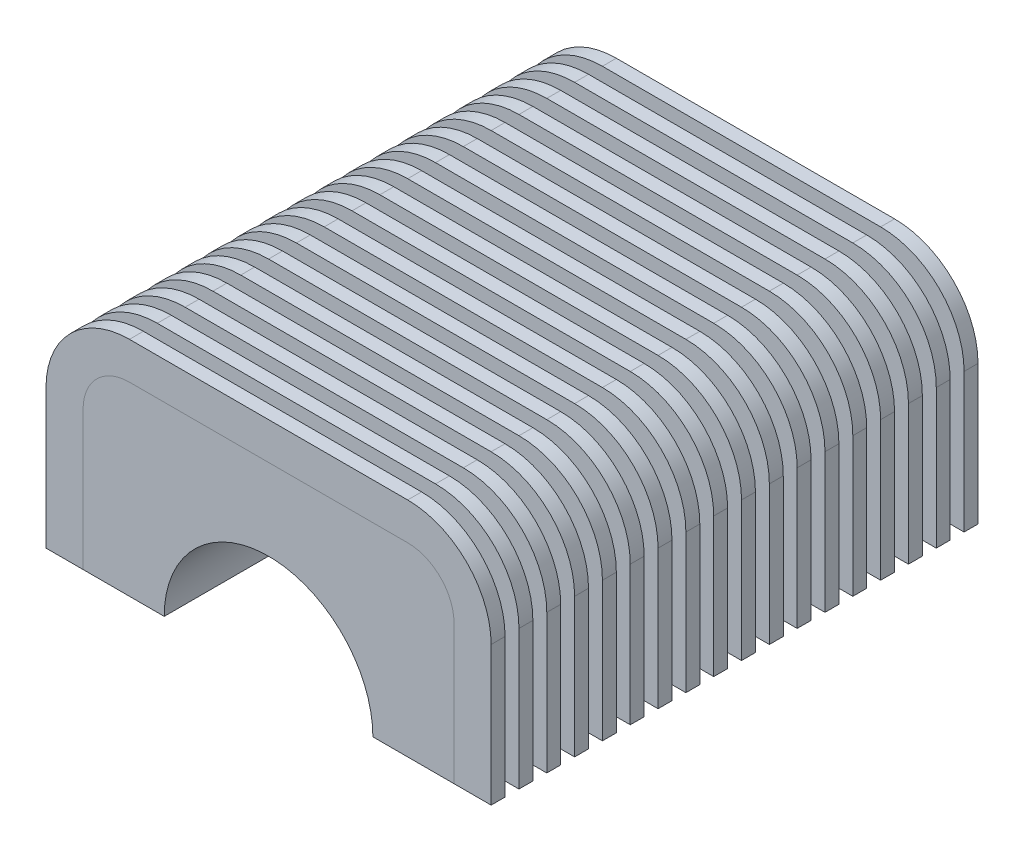
from build123d import *

# Parameters (mm, degrees)
DODANIE_WYCI_GNI_CIE1_DEPTH = 108
ZAOKR_GLENIE1_R             = 10
ZAOKR_GLENIE3_R             = 10
DODANIE_WYCI_GNI_CIE4_DEPTH = 3
SZYK_LINIOWY4_COUNT         = 18
SZYK_LINIOWY4_PITCH         = 6


with BuildPart() as part:
    # Szkic2 → Dodanie-wyciągnięcie1 (new body)
    with BuildSketch(Plane.XY):
        with BuildLine():
            Line((-40, 0), (-22.5, 0))
            ThreePointArc((-22.5, 0), (0, 22.5), (22.5, 0))
            Line((22.5, 0), (40, 0))
            Line((40, 0), (40, 40))
            Line((40, 40), (-40, 40))
            Line((-40, 40), (-40, 0))
        make_face()
    extrude(amount=-DODANIE_WYCI_GNI_CIE1_DEPTH)

    # Zaokrąglenie1
    zaokr_glenie1_edges = [part.edges().sort_by_distance(p)[0] for p in [
        (-40, 40, -54),
    ]]
    fillet(zaokr_glenie1_edges, radius=ZAOKR_GLENIE1_R)

    # Zaokrąglenie3
    zaokr_glenie3_edges = [part.edges().sort_by_distance(p)[0] for p in [
        (40, 40, -54),
    ]]
    fillet(zaokr_glenie3_edges, radius=ZAOKR_GLENIE3_R)


with BuildPart() as body_2:
    # Szkic3 → Dodanie-wyciągnięcie4 (new body)
    with BuildSketch(Plane.XY):
        with BuildLine():
            Line((-40, 0), (-48, 0))
            Line((-48, 0), (-48, 30))
            ThreePointArc((-48, 30), (-42.727922061, 42.727922061), (-30, 48))
            Line((-30, 48), (30, 48))
            ThreePointArc((30, 48), (42.727922061, 42.727922061), (48, 30))
            Line((48, 30), (48, 0))
            Line((48, 0), (40, 0))
            Line((40, 0), (40, 30))
            ThreePointArc((40, 30), (37.071067812, 37.071067812), (30, 40))
            Line((30, 40), (-30, 40))
            ThreePointArc((-30, 40), (-37.071067812, 37.071067812), (-40, 30))
            Line((-40, 30), (-40, 0))
        make_face()
    dodanie_wyci_gni_cie4 = extrude(amount=-DODANIE_WYCI_GNI_CIE4_DEPTH)


with BuildPart() as szyk_liniowy4_1:
    # Szyk liniowy4: Dodanie-wyciągnięcie4 ×18
    with Locations(*[(0, 0, -i * SZYK_LINIOWY4_PITCH) for i in range(1, SZYK_LINIOWY4_COUNT)]):
        add(dodanie_wyci_gni_cie4)


solid = Compound([part.part, body_2.part, szyk_liniowy4_1.part])
